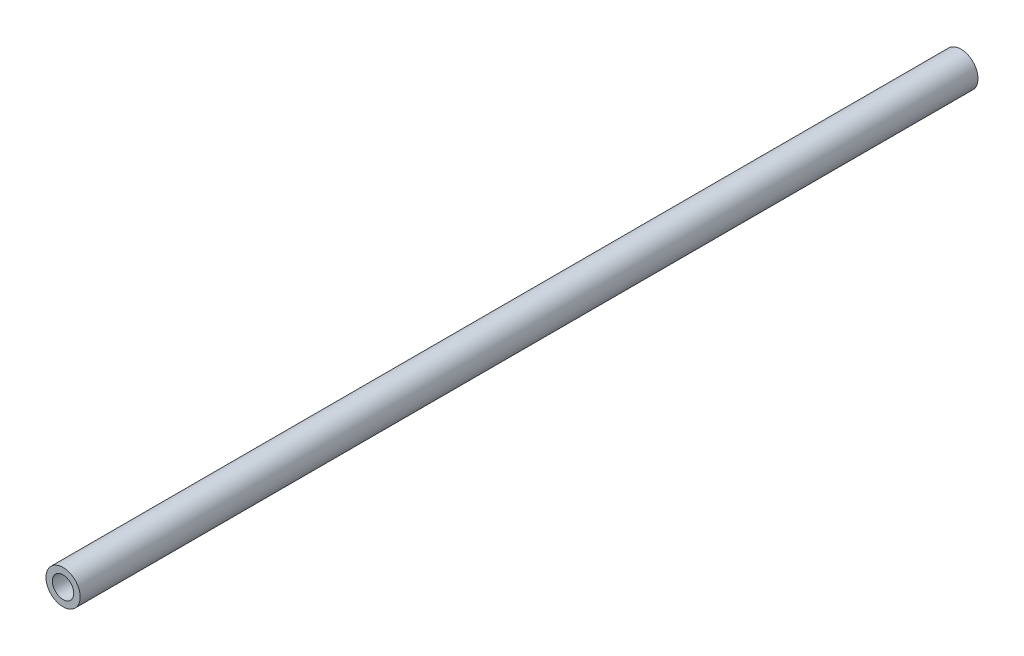
from build123d import *

# Parameters (mm, degrees)
SKETCH_1_R      = 4
SKETCH_1_R_2    = 2.5
EXTRUDE_1_DEPTH = 210


with BuildPart() as part:
    # 草图1 → 凸台-拉伸1 (new body)
    with BuildSketch(Plane.XY):
        Circle(SKETCH_1_R)
        Circle(SKETCH_1_R_2, mode=Mode.SUBTRACT)
    extrude(amount=EXTRUDE_1_DEPTH)


solid = part.part
